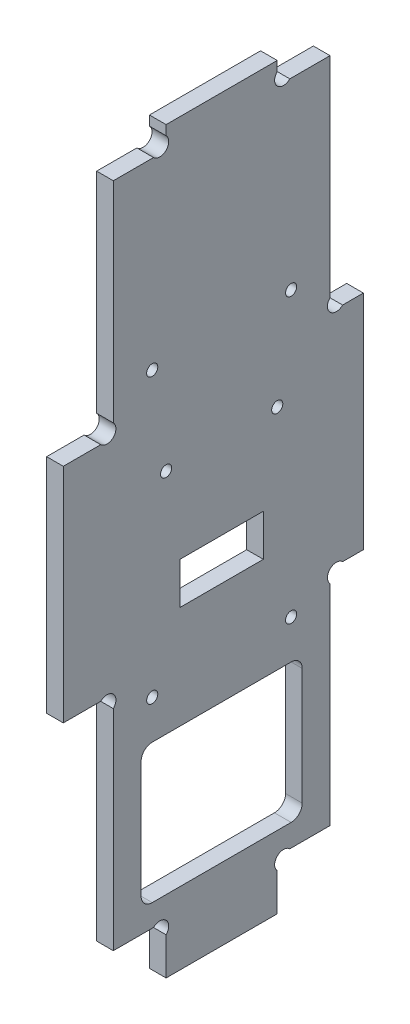
from build123d import *

# Parameters (mm, degrees)
EXTRUSION1_DEPTH        = 3
ESQUISSE2_R             = 1
ESQUISSE2_W             = 29
ESQUISSE2_H             = 25
ENL_V_MAT_EXTRU_1_DEPTH = 4
CONG_1_R                = 2
ESQUISSE3_W             = 15
ESQUISSE3_H             = 7.5
ENL_V_MAT_EXTRU_2_DEPTH = 4
ESQUISSE4_R             = 1
ENL_V_MAT_EXTRU_3_DEPTH = 4


with BuildPart() as part:
    # Esquisse1 → Extrusion1 (new body)
    with BuildSketch(Plane(origin=(0, 0, 0), x_dir=(0, 0, -1), z_dir=(1, 0, 0))):
        with BuildLine():
            Line((18.5, 6.7372583), (18.5, 0))
            Line((18.5, 0), (38.5, 0))
            Line((38.5, 0), (38.5, 6.7372583))
            ThreePointArc((38.5, 6.7372583), (38.5, 9), (40.7627417, 9))
            Line((40.7627417, 9), (48, 9))
            Line((48, 9), (48, 46.7372583))
            ThreePointArc((48, 46.7372583), (48, 49), (50.2627417, 49))
            Line((50.2627417, 49), (54, 49))
            Line((54, 49), (54, 89))
            Line((54, 89), (50.2627417, 89))
            ThreePointArc((50.2627417, 89), (48, 89), (48, 91.2627417))
            Line((48, 91.2627417), (48, 129))
            Line((48, 129), (40.7627417, 129))
            ThreePointArc((40.7627417, 129), (38.5, 129), (38.5, 131.2627417))
            Line((38.5, 131.2627417), (38.5, 133))
            Line((38.5, 133), (18.5, 133))
            Line((18.5, 133), (18.5, 131.2627417))
            ThreePointArc((18.5, 131.2627417), (18.5, 129), (16.2372583, 129))
            Line((16.2372583, 129), (9, 129))
            Line((9, 129), (9, 91.2627417))
            ThreePointArc((9, 91.2627417), (9, 89), (6.7372583, 89))
            Line((6.7372583, 89), (0, 89))
            Line((0, 89), (0, 49))
            Line((0, 49), (6.7372583, 49))
            ThreePointArc((6.7372583, 49), (9, 49), (9, 46.7372583))
            Line((9, 46.7372583), (9, 9))
            Line((9, 9), (16.2372583, 9))
            ThreePointArc((16.2372583, 9), (18.5, 9), (18.5, 6.7372583))
        make_face()
    extrude(amount=EXTRUSION1_DEPTH)

    # Esquisse2 → Enlèv. mat.-Extru.1 (cut, through all)
    with BuildSketch(Plane.ZY):
        with Locations((-38.5, 79)):
            Circle(ESQUISSE2_R)
        with Locations((-18.5, 79)):
            Circle(ESQUISSE2_R)
        with Locations((-28.5, 25.5)):
            Rectangle(ESQUISSE2_W, ESQUISSE2_H)
    extrude(amount=-ENL_V_MAT_EXTRU_1_DEPTH, mode=Mode.SUBTRACT)

    # Congé1
    cong_1_edges = [part.edges().sort_by_distance(p)[0] for p in [
        (1.5, 38, -14),
        (1.5, 13, -14),
        (1.5, 13, -43),
        (1.5, 38, -43),
    ]]
    fillet(cong_1_edges, radius=CONG_1_R)

    # Esquisse3 → Enlèv. mat.-Extru.2 (cut, through all)
    with BuildSketch(Plane.ZY):
        with Locations((-28.5, 60.25)):
            Rectangle(ESQUISSE3_W, ESQUISSE3_H)
    extrude(amount=-ENL_V_MAT_EXTRU_2_DEPTH, mode=Mode.SUBTRACT)

    # Esquisse4 → Enlèv. mat.-Extru.3 (cut, through all)
    with BuildSketch(Plane.ZY):
        with Locations((-41, 96)):
            Circle(ESQUISSE4_R)
        with Locations((-16, 96)):
            Circle(ESQUISSE4_R)
        with Locations((-41, 45)):
            Circle(ESQUISSE4_R)
        with Locations((-16, 45)):
            Circle(ESQUISSE4_R)
    extrude(amount=-ENL_V_MAT_EXTRU_3_DEPTH, mode=Mode.SUBTRACT)


solid = part.part
